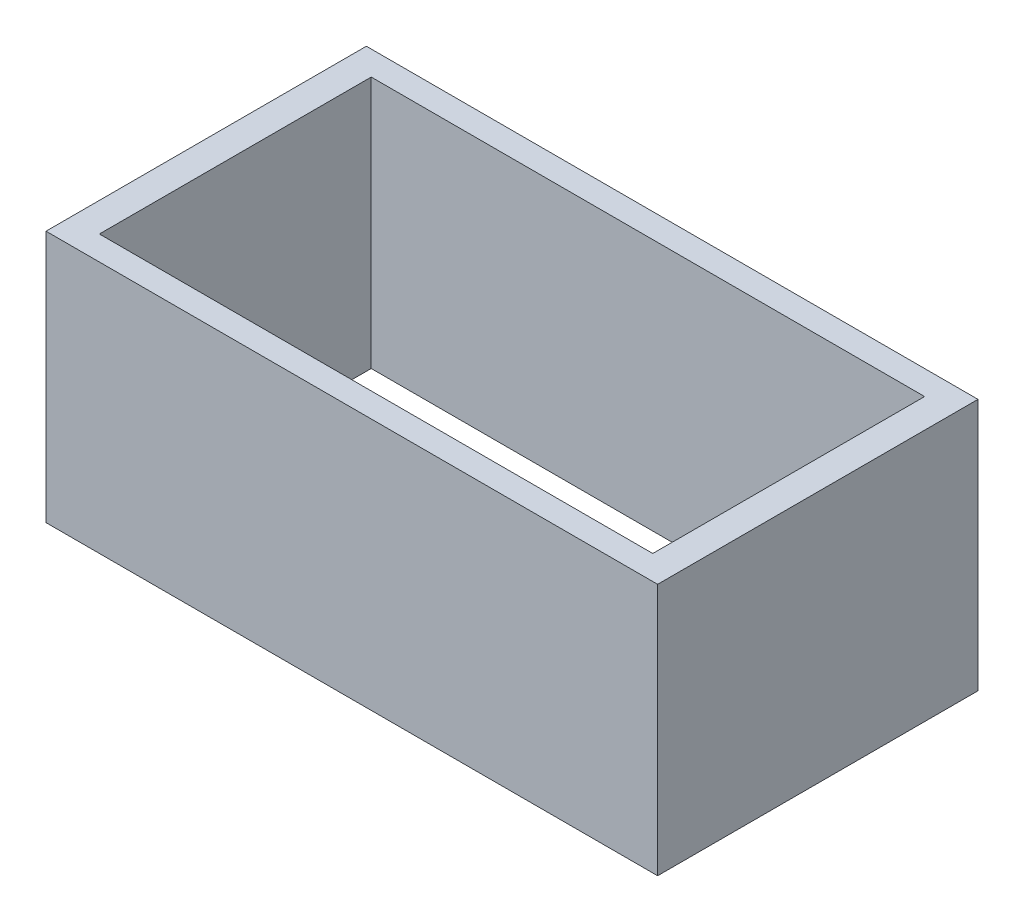
from build123d import *

# Parameters (mm, degrees)
SKETCH1_W           = 31.5
SKETCH1_H           = 16.5
BOSS_EXTRUDE1_DEPTH = 13
SKETCH2_W           = 21.5
SKETCH2_H           = 2
CUT_EXTRUDE1_DEPTH  = 14


with BuildPart() as part:
    # Sketch1 → Boss-Extrude1 (new body)
    with BuildSketch(Plane(origin=(0, 0, 0), x_dir=(1, 0, 0), z_dir=(0, 1, 0))):
        Rectangle(SKETCH1_W, SKETCH1_H)
        Polygon((10.75, 5), (-10.75, 5), (-10.75, 7), (-14.25, 7), (-14.25, -7), (-10.75, -7), (-10.75, -5), (10.75, -5), (10.75, -7), (14.25, -7), (14.25, 7), (10.75, 7), align=None, mode=Mode.SUBTRACT)
    extrude(amount=BOSS_EXTRUDE1_DEPTH)

    # Sketch2 → Cut-Extrude1 (cut, through all)
    with BuildSketch(Plane.XZ):
        with Locations((0, 6)):
            Rectangle(SKETCH2_W, SKETCH2_H)
        with Locations((0, -6)):
            Rectangle(SKETCH2_W, SKETCH2_H)
    extrude(amount=-CUT_EXTRUDE1_DEPTH, mode=Mode.SUBTRACT)


solid = part.part
